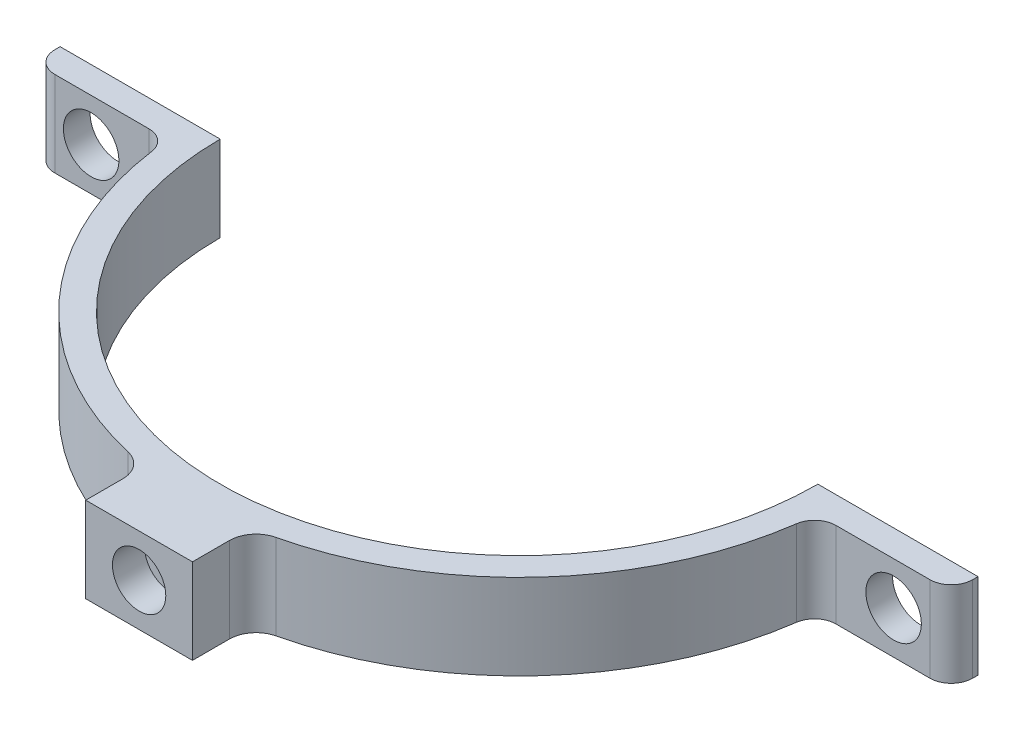
from build123d import *

# Parameters (mm, degrees)
BOSS_EXTRUDE1_DEPTH      = 10.16
FILLET1_R                = 2.54
SKETCH2_R                = 3.302
CUT_EXTRUDE1_DEPTH       = 10.16
FILLET3_R                = 2.54
BOSS_EXTRUDE2_REACH      = 69.719
BOSS_EXTRUDE2_END_RADIUS = 38.735
SKETCH4_W                = 12.7
SKETCH4_H                = 10.16
SKETCH4_2_W              = 12.7
SKETCH4_2_H              = 10.16
BOSS_EXTRUDE3_DEPTH      = 6.477
FILLET4_R                = 3.175
SKETCH5_R                = 3.175
CUT_EXTRUDE2_DEPTH       = 3.81
SKETCH7_R                = 1.905
CUT_EXTRUDE3_DEPTH       = 70.279169337


with BuildPart() as part:
    # Sketch1 → Boss-Extrude1 (new body)
    with BuildSketch(Plane(origin=(0, 0, 0), x_dir=(1, 0, 0), z_dir=(0, 1, 0))):
        with BuildLine():
            Line((-54.61, 0), (-54.61, -3.175))
            Line((-54.61, -3.175), (-38.60465775, -3.175))
            ThreePointArc((-38.60465775, -3.175), (0, -38.735), (38.60465775, -3.175))
            Line((38.60465775, -3.175), (54.61, -3.175))
            Line((54.61, -3.175), (54.61, 0))
            Line((54.61, 0), (35.56, 0))
            ThreePointArc((35.56, 0), (0, -35.56), (-35.56, 0))
            Line((-35.56, 0), (-54.61, 0))
        make_face()
    extrude(amount=BOSS_EXTRUDE1_DEPTH)

    # Fillet1
    fillet1_edges = [part.edges().sort_by_distance(p)[0] for p in [
        (38.60465775, 5.08, 3.175),
        (-38.60465775, 5.08, 3.175),
    ]]
    fillet(fillet1_edges, radius=FILLET1_R)

    # Sketch2 → Cut-Extrude1 (cut)
    with BuildSketch(Plane.XY.offset(3.175)):
        with Locations((-47.743715713, 5.08)):
            Circle(SKETCH2_R)
        with Locations((47.743715713, 5.08)):
            Circle(SKETCH2_R)
    extrude(amount=-CUT_EXTRUDE1_DEPTH, mode=Mode.SUBTRACT)

    # Fillet3
    fillet3_edges = [part.edges().sort_by_distance(p)[0] for p in [
        (-54.61, 5.08, 3.175),
        (54.61, 5.08, 3.175),
    ]]
    fillet(fillet3_edges, radius=FILLET3_R)

    # Boss-Extrude2: up to this cylinder (the profile starts outside it)
    boss_extrude2_end = Plane(origin=(0, 5.08, 0), z_dir=(0, -1, 0)) * Cylinder(BOSS_EXTRUDE2_END_RADIUS, 217.908, mode=Mode.PRIVATE)
    # Sketch4 → Boss-Extrude2 (add, up to the surface)
    with BuildSketch(Plane.XY.offset(38.735), mode=Mode.PRIVATE) as boss_extrude2_sk1:
        with Locations((0, 5.08)):
            Rectangle(SKETCH4_W, SKETCH4_H)
    boss_extrude2_tool1 = extrude(boss_extrude2_sk1.sketch, amount=-BOSS_EXTRUDE2_REACH, mode=Mode.PRIVATE) - boss_extrude2_end
    add(boss_extrude2_tool1.solids().sort_by_distance((0, 5.08, 38.735))[0])
    add(boss_extrude2_tool1.solids().sort_by_distance((0, 5.08, 38.735))[1])

    # Sketch4_2 → Boss-Extrude3 (add)
    with BuildSketch(Plane.XY.offset(38.735)):
        with Locations((0, 5.08)):
            Rectangle(SKETCH4_2_W, SKETCH4_2_H)
    extrude(amount=BOSS_EXTRUDE3_DEPTH)

    # Fillet4
    fillet4_edges = [part.edges().sort_by_distance(p)[0] for p in [
        (-6.35, 5.08, 38.210963414),
        (6.35, 5.08, 38.210963414),
    ]]
    fillet(fillet4_edges, radius=FILLET4_R)

    # Sketch5 → Cut-Extrude2 (cut)
    with BuildSketch(Plane.XY.offset(45.212)):
        with Locations((0, 5.08)):
            Circle(SKETCH5_R)
    extrude(amount=-CUT_EXTRUDE2_DEPTH, mode=Mode.SUBTRACT)

    # Sketch7 → Cut-Extrude3 (cut, through all)
    with BuildSketch(Plane.XY.offset(41.402)):
        with Locations((0, 5.08)):
            Circle(SKETCH7_R)
    extrude(amount=-CUT_EXTRUDE3_DEPTH, mode=Mode.SUBTRACT)


solid = part.part
